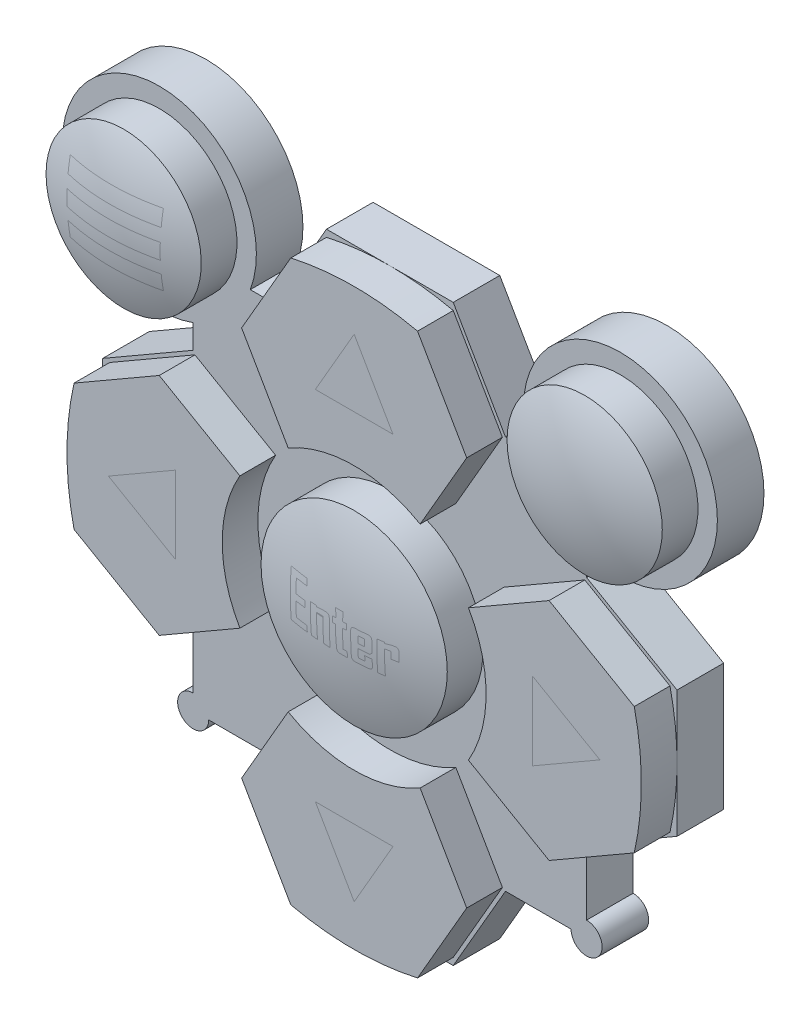
from build123d import *

# Parameters (mm, degrees)
SKETCH2_W            = 37
SKETCH2_H            = 37
BOSS_EXTRUDE1_DEPTH  = 3
SKETCH3_R            = 6
BOSS_EXTRUDE2_DEPTH  = 2.3
SKETCH6_R            = 18.5
SKETCH6_R_2          = 8.5
BOSS_EXTRUDE3_DEPTH  = 2.3
CUT_EXTRUDE2_DEPTH   = 2.3
CIRPATTERN1_COUNT    = 4
CUT_EXTRUDE3_DEPTH   = 2.3
CIRPATTERN2_COUNT    = 4
CUT_EXTRUDE5_DEPTH   = 3
CIRPATTERN7_COUNT    = 4
MIRROR2_COPY_1_DEPTH = 3
MIRROR2_COPY_2_DEPTH = 3
MIRROR2_COPY_3_DEPTH = 3
SKETCH11_R           = 6.25
BOSS_EXTRUDE4_DEPTH  = 3
CIRPATTERN9_COUNT    = 2
CIRPATTERN9_ANGLE    = 90
SKETCH12_R           = 5
BOSS_EXTRUDE5_DEPTH  = 2.3
CIRPATTERN10_COUNT   = 2
CIRPATTERN10_ANGLE   = 90
CIRPATTERN11_COUNT   = 2
CIRPATTERN11_ANGLE   = 90
SCALE1_SCALE         = 0.965
SKETCH19_W           = 7
SKETCH19_H           = 6.5
CUT_EXTRUDE6_DEPTH   = 3
SKETCH20_W           = 5.6
SKETCH20_H           = 1.8
CUT_EXTRUDE7_DEPTH   = 1.5
SKETCH28_W           = 7
SKETCH28_H           = 6.5
CUT_EXTRUDE10_DEPTH  = 3
SKETCH30_W           = 5.6
SKETCH30_H           = 1.8
CUT_EXTRUDE11_DEPTH  = 1.5
CIRPATTERN12_COUNT   = 4
SKETCH33_W           = 7
SKETCH33_H           = 6.5
CUT_EXTRUDE12_DEPTH  = 3
SKETCH35_W           = 5.6
SKETCH35_H           = 1.8
CUT_EXTRUDE13_DEPTH  = 1.5
SKETCH37_W           = 7
SKETCH37_H           = 6.5
CUT_EXTRUDE14_DEPTH  = 3
SKETCH39_W           = 5.6
SKETCH39_H           = 1.8
CUT_EXTRUDE15_DEPTH  = 1.5


with BuildPart() as part:
    # Sketch2 → Boss-Extrude1 (new body)
    with BuildSketch(Plane.XY):
        Rectangle(SKETCH2_W, SKETCH2_H)
    extrude(amount=BOSS_EXTRUDE1_DEPTH)

    # Sketch3 → Boss-Extrude2 (add)
    with BuildSketch(Plane.XY.offset(3)):
        Circle(SKETCH3_R)
    extrude(amount=BOSS_EXTRUDE2_DEPTH)

    # Sketch5 → Revolve1 (revolve)
    with BuildSketch(Plane(origin=(0, 0, 0), x_dir=(-1, 0, 0), z_dir=(0, -1, 0))):
        with BuildLine():
            Line((6, -5.3), (0, -5.3))
            Line((0, -5.3), (0, -6.3))
            ThreePointArc((0, -6.3), (3.041381265, -6.048287591), (6, -5.3))
        make_face()
    revolve(axis=Axis((0, 0, 5.3), (0, 0, 1)))

    # Sketch6 → Boss-Extrude3 (add)
    with BuildSketch(Plane.XY.offset(3)):
        Circle(SKETCH6_R)
        Circle(SKETCH6_R_2, mode=Mode.SUBTRACT)
    extrude(amount=BOSS_EXTRUDE3_DEPTH)

    # Sketch8 → Cut-Extrude2 (cut)
    with BuildSketch(Plane.XY.offset(5.3)):
        with BuildLine():
            ThreePointArc((4.25, 7.361215932), (6.01040764, 6.01040764), (7.361215932, 4.25))
            Line((7.361215932, 4.25), (16.02146997, 9.25))
            ThreePointArc((16.02146997, 9.25), (13.081475452, 13.081475452), (9.25, 16.02146997))
            Line((9.25, 16.02146997), (4.25, 7.361215932))
        make_face()
    cut_extrude2 = extrude(amount=-CUT_EXTRUDE2_DEPTH, mode=Mode.SUBTRACT)

    # CirPattern1: Cut-Extrude2 ×4 about axis
    cirpattern1_axis = Axis((0, 0, 5.3), (0, 0, 1))
    for i in range(1, CIRPATTERN1_COUNT):
        add(cut_extrude2.rotate(cirpattern1_axis, i * 360 / CIRPATTERN1_COUNT), mode=Mode.SUBTRACT)

    # Sketch9 → Cut-Extrude3 (cut)
    with BuildSketch(Plane.XY.offset(5.3)):
        with BuildLine():
            Line((16.02146997, 9.25), (12.557368355, 7.25))
            Line((12.557368355, 7.25), (18.043966792, 4.082310915))
            ThreePointArc((18.043966792, 4.082310915), (17.227586832, 6.742421815), (16.02146997, 9.25))
        make_face()
        with BuildLine():
            Line((18.043966792, -4.082310915), (12.557368355, -7.25))
            Line((12.557368355, -7.25), (16.02146997, -9.25))
            ThreePointArc((16.02146997, -9.25), (17.227586832, -6.742421815), (18.043966792, -4.082310915))
        make_face()
    cut_extrude3 = extrude(amount=-CUT_EXTRUDE3_DEPTH, mode=Mode.SUBTRACT)

    # CirPattern2: Cut-Extrude3 ×4 about axis
    cirpattern2_axis = Axis((0, 0, 0), (0, 0, 1))
    for i in range(1, CIRPATTERN2_COUNT):
        add(cut_extrude3.rotate(cirpattern2_axis, i * 360 / CIRPATTERN2_COUNT), mode=Mode.SUBTRACT)

    # Sketch10 → Cut-Extrude5 (cut)
    with BuildSketch(Plane.XY.offset(3)):
        with BuildLine():
            Line((7.447468172, -12.671376657), (4.082310915, -18.5))
            Line((4.082310915, -18.5), (18.5, -18.5))
            Line((18.5, -18.5), (13.378483438, -13.378483438))
            ThreePointArc((13.378483438, -13.378483438), (12.288693225, -13.595256189), (11.671376657, -12.671376657))
            Line((11.671376657, -12.671376657), (7.447468172, -12.671376657))
        make_face()
    cut_extrude5 = extrude(amount=-CUT_EXTRUDE5_DEPTH, mode=Mode.SUBTRACT)

    # CirPattern7: Cut-Extrude5 ×4 about axis
    cirpattern7_axis = Axis((0, 0, 0), (0, 0, 1))
    for i in range(1, CIRPATTERN7_COUNT):
        add(cut_extrude5.rotate(cirpattern7_axis, i * 360 / CIRPATTERN7_COUNT), mode=Mode.SUBTRACT)

    # Mirror2: Cut-Extrude5 across plane
    add(cut_extrude5.mirror(Plane(origin=(0, 0, 0), x_dir=(0, 0, 1), z_dir=(0.707106781, -0.707106781, 0))), mode=Mode.SUBTRACT)

    # Mirror2 copy 1 sketch → Mirror2 copy 1 (cut)
    with BuildSketch(Plane.XY.offset(3)):
        with BuildLine():
            Line((7.447468172, 12.671376657), (4.082310915, 18.5))
            Line((4.082310915, 18.5), (18.5, 18.5))
            Line((18.5, 18.5), (13.378483438, 13.378483438))
            ThreePointArc((13.378483438, 13.378483438), (12.288693225, 13.595256189), (11.671376657, 12.671376657))
            Line((11.671376657, 12.671376657), (7.447468172, 12.671376657))
        make_face()
    extrude(amount=-MIRROR2_COPY_1_DEPTH, mode=Mode.SUBTRACT)

    # Mirror2 copy 2 sketch → Mirror2 copy 2 (cut)
    with BuildSketch(Plane(origin=(0, 0, 3), x_dir=(0, -1, 0), z_dir=(0, 0, 1))):
        with BuildLine():
            Line((7.447468172, 12.671376657), (4.082310915, 18.5))
            Line((4.082310915, 18.5), (18.5, 18.5))
            Line((18.5, 18.5), (13.378483438, 13.378483438))
            ThreePointArc((13.378483438, 13.378483438), (12.288693225, 13.595256189), (11.671376657, 12.671376657))
            Line((11.671376657, 12.671376657), (7.447468172, 12.671376657))
        make_face()
    extrude(amount=-MIRROR2_COPY_2_DEPTH, mode=Mode.SUBTRACT)

    # Mirror2 copy 3 sketch → Mirror2 copy 3 (cut)
    with BuildSketch(Plane(origin=(0, 0, 3), x_dir=(-1, 0, 0), z_dir=(0, 0, 1))):
        with BuildLine():
            Line((7.447468172, 12.671376657), (4.082310915, 18.5))
            Line((4.082310915, 18.5), (18.5, 18.5))
            Line((18.5, 18.5), (13.378483438, 13.378483438))
            ThreePointArc((13.378483438, 13.378483438), (12.288693225, 13.595256189), (11.671376657, 12.671376657))
            Line((11.671376657, 12.671376657), (7.447468172, 12.671376657))
        make_face()
    extrude(amount=-MIRROR2_COPY_3_DEPTH, mode=Mode.SUBTRACT)

    # Sketch11 → Boss-Extrude4 (add)
    with BuildSketch(Plane.XY):
        with Locations((14.849242405, 14.849242405)):
            Circle(SKETCH11_R)
    boss_extrude4 = extrude(amount=BOSS_EXTRUDE4_DEPTH)

    # CirPattern9: Boss-Extrude4 ×2 about axis
    cirpattern9_axis = Axis((0, 0, 5.3), (0, 0, 1))
    for i in range(1, CIRPATTERN9_COUNT):
        add(boss_extrude4.rotate(cirpattern9_axis, i * CIRPATTERN9_ANGLE / (CIRPATTERN9_COUNT - 1)))

    # Sketch12 → Boss-Extrude5 (add)
    with BuildSketch(Plane.XY.offset(3)):
        with Locations((14.849242405, 14.849242405)):
            Circle(SKETCH12_R)
    boss_extrude5 = extrude(amount=BOSS_EXTRUDE5_DEPTH)

    # Sketch14 → Revolve2 (revolve)
    with BuildSketch(Plane(origin=(14.849242405, 0, 0), x_dir=(0, 0, -1), z_dir=(1, 0, 0))):
        with BuildLine():
            Line((-6.3, 14.849242405), (-5.3, 14.849242405))
            Line((-5.3, 14.849242405), (-5.3, 9.849242405))
            ThreePointArc((-5.3, 9.849242405), (-6.047548784, 12.299732648), (-6.3, 14.849242405))
        make_face()
    revolve2 = revolve(axis=Axis((14.849242405, 14.849242405, 5.3), (0, 0, 1)))

    # CirPattern10: Boss-Extrude5 ×2 about axis
    cirpattern10_axis = Axis((0, 0, 5.3), (0, 0, 1))
    for i in range(1, CIRPATTERN10_COUNT):
        add(boss_extrude5.rotate(cirpattern10_axis, i * CIRPATTERN10_ANGLE / (CIRPATTERN10_COUNT - 1)))

    # CirPattern11: Revolve2 ×2 about axis
    cirpattern11_axis = Axis((0, 0, 5.3), (0, 0, 1))
    for i in range(1, CIRPATTERN11_COUNT):
        add(revolve2.rotate(cirpattern11_axis, i * CIRPATTERN11_ANGLE / (CIRPATTERN11_COUNT - 1)))


with BuildPart() as part_1:
    # Scale1: scaled about (0, 0, 0)
    add(part.part.scale(SCALE1_SCALE))

    # Sketch19 → Cut-Extrude6 (cut)
    with BuildSketch(Plane(origin=(0, 0, 0), x_dir=(-1, 0, 0), z_dir=(0, 0, -1))):
        Rectangle(SKETCH19_W, SKETCH19_H)
    extrude(amount=-CUT_EXTRUDE6_DEPTH, mode=Mode.SUBTRACT)

    # Sketch20 → Cut-Extrude7 (cut)
    with BuildSketch(Plane(origin=(0, 0, 0), x_dir=(-1, 0, 0), z_dir=(0, 0, -1))):
        with Locations((0, 4.15)):
            Rectangle(SKETCH20_W, SKETCH20_H)
        with Locations((0, -4.15)):
            Rectangle(SKETCH20_W, SKETCH20_H)
    extrude(amount=-CUT_EXTRUDE7_DEPTH, mode=Mode.SUBTRACT)

    # Sketch28 → Cut-Extrude10 (cut)
    with BuildSketch(Plane(origin=(-9.998493026, 1.351076982, 0), x_dir=(-1, 0, 0), z_dir=(0, 0, -1))):
        with Locations((1.751506974, -1.351076982)):
            Rectangle(SKETCH28_W, SKETCH28_H)
    cut_extrude10 = extrude(amount=-CUT_EXTRUDE10_DEPTH, mode=Mode.SUBTRACT)

    # Sketch30 → Cut-Extrude11 (cut)
    with BuildSketch(Plane(origin=(-9.998493026, 1.351076982, 0), x_dir=(-1, 0, 0), z_dir=(0, 0, -1))):
        with Locations((1.751506974, 2.798923018)):
            Rectangle(SKETCH30_W, SKETCH30_H)
        with Locations((1.751506974, -5.501076982)):
            Rectangle(SKETCH30_W, SKETCH30_H)
    cut_extrude11 = extrude(amount=-CUT_EXTRUDE11_DEPTH, mode=Mode.SUBTRACT)

    # CirPattern12: Cut-Extrude10, Cut-Extrude11 ×4 about axis
    cirpattern12_axis = Axis((0, 0, 0), (0, 0, 1))
    for i in range(1, CIRPATTERN12_COUNT):
        add(cut_extrude10.rotate(cirpattern12_axis, i * 360 / CIRPATTERN12_COUNT), mode=Mode.SUBTRACT)
        add(cut_extrude11.rotate(cirpattern12_axis, i * 360 / CIRPATTERN12_COUNT), mode=Mode.SUBTRACT)

    # Sketch33 → Cut-Extrude12 (cut)
    with BuildSketch(Plane(origin=(-14.368957264, 14.283753363, 0), x_dir=(-1, 0, 0), z_dir=(0, 0, -1))):
        with Locations((-0.039438343, 0.045765558)):
            Rectangle(SKETCH33_W, SKETCH33_H)
    extrude(amount=-CUT_EXTRUDE12_DEPTH, mode=Mode.SUBTRACT)

    # Sketch35 → Cut-Extrude13 (cut)
    with BuildSketch(Plane(origin=(-14.368957264, 14.283753363, 0), x_dir=(-1, 0, 0), z_dir=(0, 0, -1))):
        with Locations((-0.039438343, 4.195765558)):
            Rectangle(SKETCH35_W, SKETCH35_H)
        with Locations((-0.039438343, -4.104234442)):
            Rectangle(SKETCH35_W, SKETCH35_H)
    extrude(amount=-CUT_EXTRUDE13_DEPTH, mode=Mode.SUBTRACT)

    # Sketch37 → Cut-Extrude14 (cut)
    with BuildSketch(Plane(origin=(13.371321797, 14.128872217, 0), x_dir=(-1, 0, 0), z_dir=(0, 0, -1))):
        with Locations((-0.958197123, 0.200646703)):
            Rectangle(SKETCH37_W, SKETCH37_H)
    extrude(amount=-CUT_EXTRUDE14_DEPTH, mode=Mode.SUBTRACT)

    # Sketch39 → Cut-Extrude15 (cut)
    with BuildSketch(Plane(origin=(13.371321797, 14.128872217, 0), x_dir=(-1, 0, 0), z_dir=(0, 0, -1))):
        with Locations((-0.958197123, 4.350646703)):
            Rectangle(SKETCH39_W, SKETCH39_H)
        with Locations((-0.958197123, -3.949353297)):
            Rectangle(SKETCH39_W, SKETCH39_H)
    extrude(amount=-CUT_EXTRUDE15_DEPTH, mode=Mode.SUBTRACT)


solid = part_1.part
